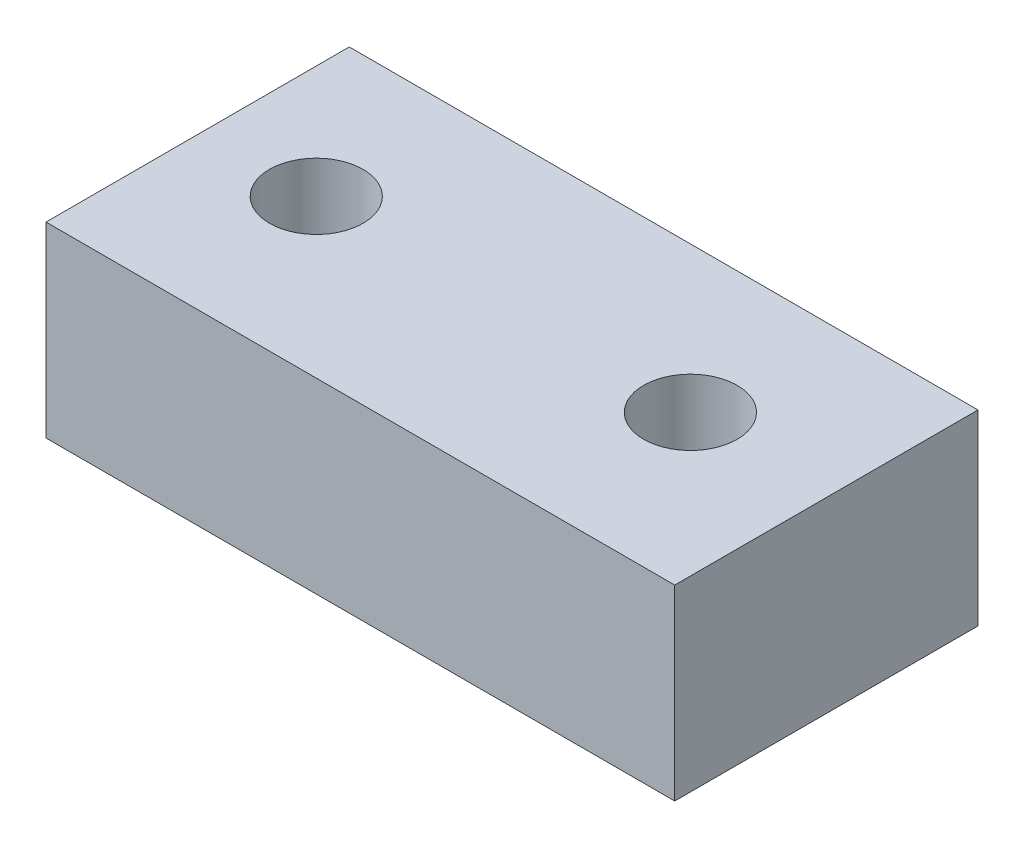
from build123d import *

# Parameters (mm, degrees)
SKETCH1_W           = 13.443515321
SKETCH1_H           = 6.48485985
SKETCH1_R           = 1
BOSS_EXTRUDE1_DEPTH = 4


with BuildPart() as part:
    # Sketch1 → Boss-Extrude1 (new body)
    with BuildSketch(Plane(origin=(0, 0, 0), x_dir=(1, 0, 0), z_dir=(0, 1, 0))):
        with Locations((0.308676607, -0.123491193)):
            Rectangle(SKETCH1_W, SKETCH1_H)
        with Locations((-4, 0)):
            Circle(SKETCH1_R, mode=Mode.SUBTRACT)
        with Locations((4, 0)):
            Circle(SKETCH1_R, mode=Mode.SUBTRACT)
    extrude(amount=BOSS_EXTRUDE1_DEPTH)


solid = part.part
